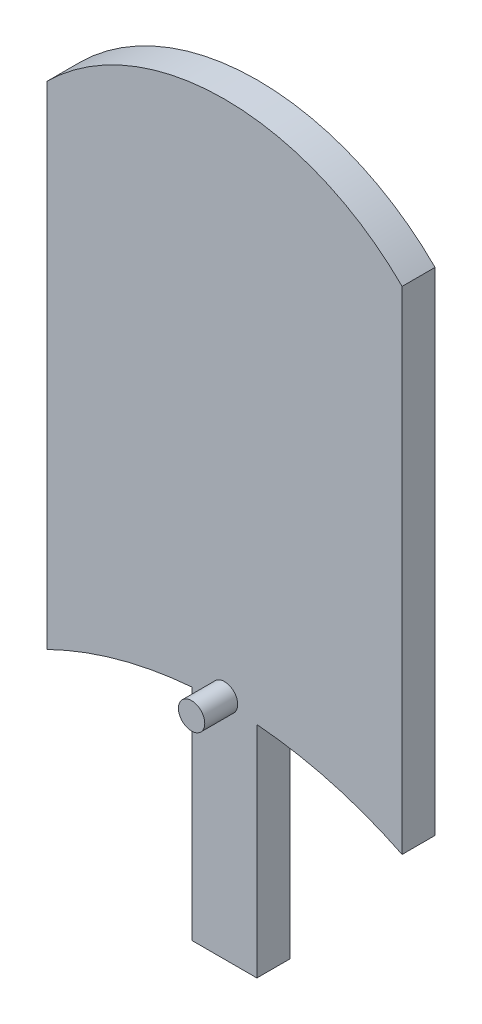
from build123d import *

# Parameters (mm, degrees)
BOSS_EXTRUDE1_DEPTH = 3.175
BOSS_EXTRUDE2_DEPTH = 3.175
SKETCH3_W           = 6.236959702
SKETCH3_H           = 41.352711554
BOSS_EXTRUDE3_DEPTH = 3.175
SKETCH4_R           = 1.27
BOSS_EXTRUDE4_DEPTH = 3.175
BOSS_EXTRUDE5_REACH = 20.766
SKETCH6_W           = 0.889
SKETCH6_H           = 43.066281197
CUT_EXTRUDE1_REACH  = 11.525


with BuildPart() as part:
    # Sketch1 → Boss-Extrude1 (new body)
    with BuildSketch(Plane.XY):
        with BuildLine():
            Line((-17.114253333, -23.707583903), (-17.114253333, 23.707583903))
            ThreePointArc((-17.114253333, 23.707583903), (0, 30.782200079), (17.114253333, 23.707583903))
            Line((17.114253333, 23.707583903), (17.114253333, -23.707583903))
            ThreePointArc((17.114253333, -23.707583903), (0, -19.732802645), (-17.114253333, -23.707583903))
        make_face()
    extrude(amount=BOSS_EXTRUDE1_DEPTH)

    # Sketch2 → Boss-Extrude2 (add)
    with BuildSketch(Plane(origin=(0, 0, 0), x_dir=(-1, 0, 0), z_dir=(0, 0, -1))):
        with BuildLine():
            Line((-1.65128862, -19.767928257), (-1.65128862, 22.268343179))
            Line((-1.65128862, 22.268343179), (-1.65128862, 23.29835294))
            Line((-1.65128862, 23.29835294), (-2.853426735, 23.29835294))
            Line((-2.853426735, 23.29835294), (-2.853426735, -19.837781624))
            ThreePointArc((-2.853426735, -19.837781624), (-2.25262846, -19.798194915), (-1.65128862, -19.767928257))
        make_face()
        with BuildLine():
            Line((1.65128862, 23.29835294), (1.65128862, 22.268343179))
            Line((1.65128862, 22.268343179), (1.65128862, -19.767928257))
            ThreePointArc((1.65128862, -19.767928257), (2.25262846, -19.798194915), (2.853426735, -19.837781624))
            Line((2.853426735, -19.837781624), (2.853426735, 23.29835294))
            Line((2.853426735, 23.29835294), (1.65128862, 23.29835294))
        make_face()
    extrude(amount=BOSS_EXTRUDE2_DEPTH)

    # Sketch3 → Boss-Extrude3 (add)
    with BuildSketch(Plane.XY.offset(3.175)):
        with Locations((0, -20.33746726)):
            Rectangle(SKETCH3_W, SKETCH3_H)
    extrude(amount=-BOSS_EXTRUDE3_DEPTH)

    # Sketch4 → Boss-Extrude4 (add)
    with BuildSketch(Plane.XY.offset(3.175)):
        with Locations((0, -19.105823038)):
            Circle(SKETCH4_R)
    extrude(amount=BOSS_EXTRUDE4_DEPTH)

    # Sketch6 → Boss-Extrude5 (add, up to next)
    with BuildSketch(Plane.ZY.offset(-1.65128862), mode=Mode.PRIVATE) as boss_extrude5_sk1:
        with Locations((-2.7305, 1.765212341)):
            Rectangle(SKETCH6_W, SKETCH6_H)
    boss_extrude5_tool1 = extrude(boss_extrude5_sk1.sketch, amount=BOSS_EXTRUDE5_REACH, mode=Mode.PRIVATE) - part.part
    add(boss_extrude5_tool1.solids().sort_by_distance((1.651289, 1.765212, -2.7305))[0])

    # Sketch8 → Cut-Extrude1 (cut, up to next)
    with BuildSketch(Plane(origin=(0, 0, -3.175), x_dir=(-1, 0, 0), z_dir=(0, 0, -1)), mode=Mode.PRIVATE) as cut_extrude1_sk1:
        Polygon((0, 23.29835294), (-1.016, 23.29835294), (-1.016, -19.767928257), (1.016, -19.767928257), (1.016, 23.29835294), align=None)
    cut_extrude1_tool1 = extrude(cut_extrude1_sk1.sketch, amount=-CUT_EXTRUDE1_REACH, mode=Mode.PRIVATE) & part.part
    add(cut_extrude1_tool1.solids().sort_by_distance((0, 1.765212, -3.175))[0], mode=Mode.SUBTRACT)


solid = part.part
